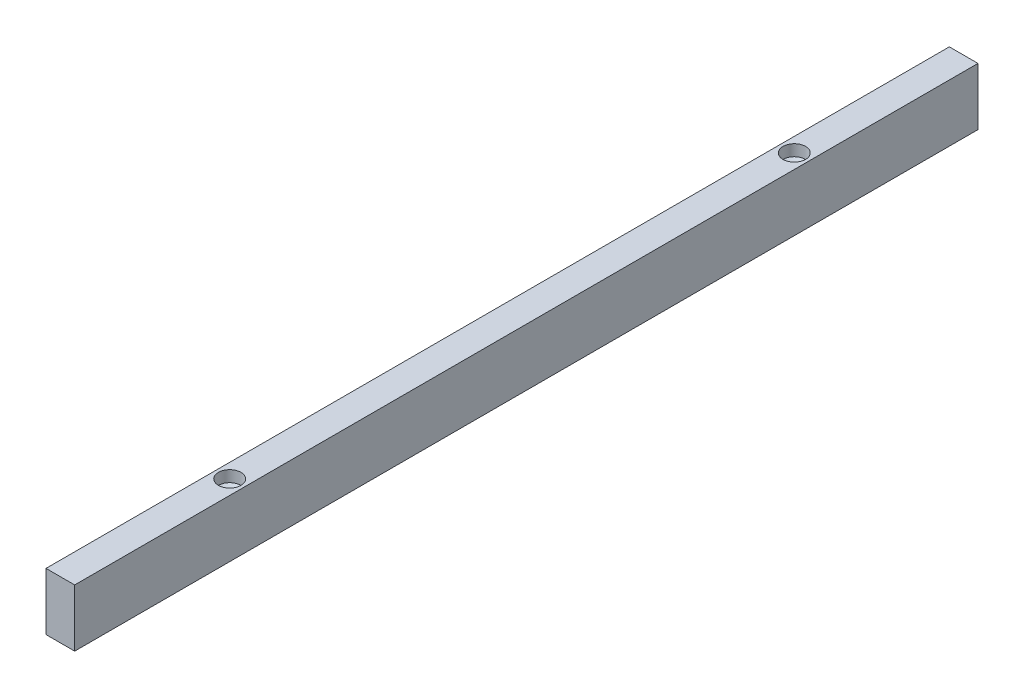
from build123d import *

# Parameters (mm, degrees)
BOSS_EXTRUDE1_DEPTH      = 200
BOSS_EXTRUDE1_DEPTH_BACK = 200
SKETCH1_W                = 12.7
SKETCH1_H                = 25.4


with BuildPart() as part:
    # Sketch1 → Boss-Extrude1 (new, two sides: drawn at the far end of the back side and taken through both)
    with BuildSketch(Plane.XY.offset(-BOSS_EXTRUDE1_DEPTH_BACK)):
        Rectangle(SKETCH1_W, SKETCH1_H)
    extrude(amount=BOSS_EXTRUDE1_DEPTH + BOSS_EXTRUDE1_DEPTH_BACK)

    # Sketch2 → Cut-Revolve1 (revolve, cut)
    with BuildSketch(Plane(origin=(0, 0, 0), x_dir=(0, 0, -1), z_dir=(1, 0, 0))):
        Polygon((-125, 12.7), (-120, 12.7), (-120, 7.7), (-122, 6.545299462), (-122, -2.3), (-123.35, -3.079422863), (-123.35, -12.7), (-125, -12.7), align=None)
    cut_revolve1 = revolve(axis=Axis((0, -12.7, 125), (0, 1, 0)), mode=Mode.SUBTRACT)

    # Mirror1: Cut-Revolve1 across plane
    add(cut_revolve1.mirror(Plane.XY), mode=Mode.SUBTRACT)


solid = part.part
